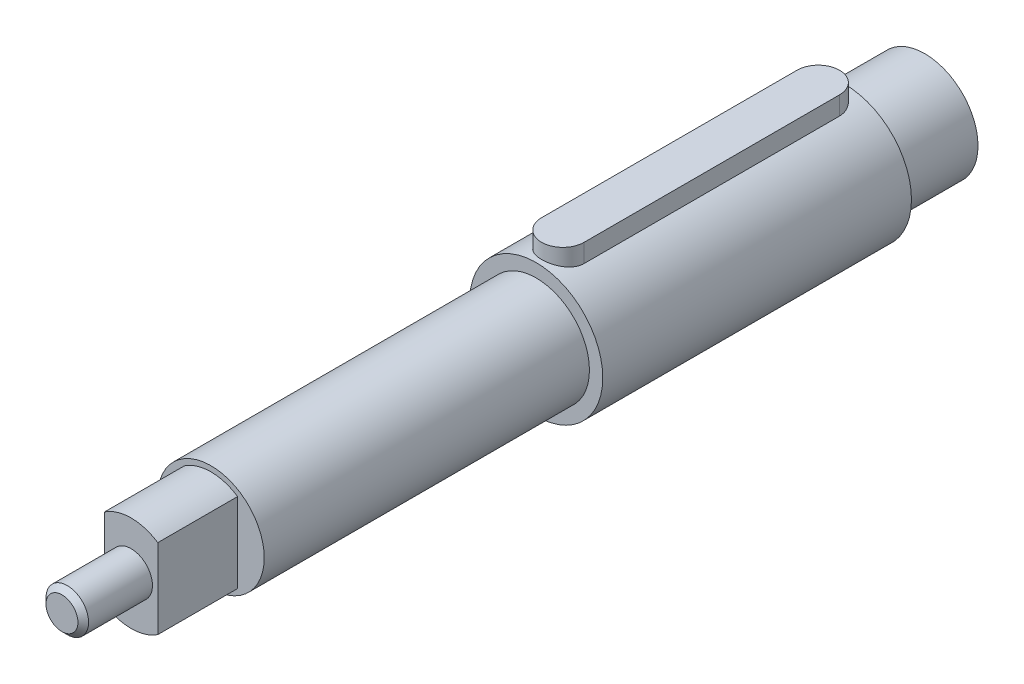
from build123d import *

# Parameters (mm, degrees)
CROQUIS1_R              = 12.5
SALIENTE_EXTRUIR1_DEPTH = 58
CORTAR_EXTRUIR1_START   = 9.3
CORTAR_EXTRUIR1_DEPTH   = 60
CROQUIS3_R              = 10
SALIENTE_EXTRUIR2_DEPTH = 15
CROQUIS4_R              = 10
SALIENTE_EXTRUIR3_DEPTH = 61.1
SALIENTE_EXTRUIR4_DEPTH = 15
CROQUIS6_R              = 4
SALIENTE_EXTRUIR5_DEPTH = 13
CHAFL_N1_SIZE           = 1
SALIENTE_EXTRUIR6_DEPTH = 6


with BuildPart() as part:
    # Croquis1 → Saliente-Extruir1 (new body)
    with BuildSketch(Plane.XY):
        Circle(CROQUIS1_R)
    extrude(amount=SALIENTE_EXTRUIR1_DEPTH)

    # Croquis2 → Cortar-Extruir1 (cut)
    with BuildSketch(Plane(origin=(0, 0, 0), x_dir=(1, 0, 0), z_dir=(0, 1, 0)).offset(CORTAR_EXTRUIR1_START)):
        with BuildLine():
            Line((4, -5), (4, -53))
            ThreePointArc((4, -53), (0, -57), (-4, -53))
            Line((-4, -53), (-4, -5))
            ThreePointArc((-4, -5), (0, -1), (4, -5))
        make_face()
    extrude(amount=CORTAR_EXTRUIR1_DEPTH, mode=Mode.SUBTRACT)

    # Croquis3 → Saliente-Extruir2 (add)
    with BuildSketch(Plane(origin=(0, 0, 0), x_dir=(-1, 0, 0), z_dir=(0, 0, -1))):
        Circle(CROQUIS3_R)
    extrude(amount=SALIENTE_EXTRUIR2_DEPTH)

    # Croquis4 → Saliente-Extruir3 (add)
    with BuildSketch(Plane.XY.offset(58)):
        Circle(CROQUIS4_R)
    extrude(amount=SALIENTE_EXTRUIR3_DEPTH)

    # Croquis5 → Saliente-Extruir4 (add)
    with BuildSketch(Plane.XY.offset(119.1)):
        with BuildLine():
            Line((-5, 7.483314774), (-5, -7.483314774))
            ThreePointArc((-5, -7.483314774), (0, -9), (5, -7.483314774))
            Line((5, -7.483314774), (5, 7.483314774))
            ThreePointArc((5, 7.483314774), (0, 9), (-5, 7.483314774))
        make_face()
    extrude(amount=SALIENTE_EXTRUIR4_DEPTH)

    # Croquis6 → Saliente-Extruir5 (add)
    with BuildSketch(Plane.XY.offset(134.1)):
        Circle(CROQUIS6_R)
    extrude(amount=SALIENTE_EXTRUIR5_DEPTH)

    # Chaflán1
    chafl_n1_edges = [part.edges().sort_by_distance(p)[0] for p in [
        (-4, 0, 147.1),
    ]]
    chamfer(chafl_n1_edges, length=CHAFL_N1_SIZE)


with BuildPart() as body_2:
    # Croquis7 → Saliente-Extruir6 (new body)
    with BuildSketch(Plane(origin=(0, 9.3, 0), x_dir=(1, 0, 0), z_dir=(0, 1, 0))):
        with BuildLine():
            Line((-4, -5), (-4, -53))
            ThreePointArc((-4, -53), (0, -57), (4, -53))
            Line((4, -53), (4, -5))
            ThreePointArc((4, -5), (0, -1), (-4, -5))
        make_face()
    extrude(amount=SALIENTE_EXTRUIR6_DEPTH)


solid = Compound([part.part, body_2.part])
